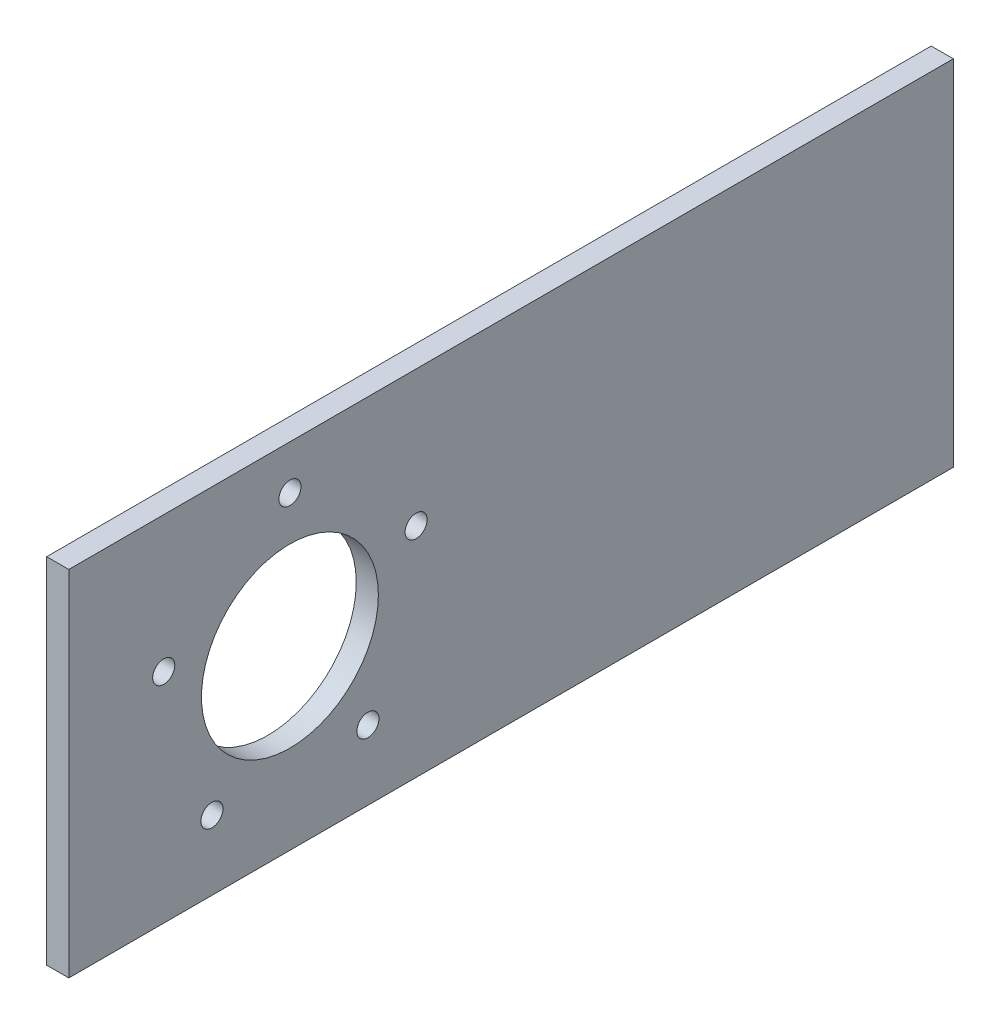
from build123d import *

# Parameters (mm, degrees)
SKETCH1_W           = 254
SKETCH1_H           = 101.6
SKETCH1_R           = 25.4
BOSS_EXTRUDE1_DEPTH = 3.175
SKETCH2_R           = 3.175
CUT_EXTRUDE1_DEPTH  = 7.35
CIRPATTERN1_COUNT   = 5


with BuildPart() as part:
    # Sketch1 → Boss-Extrude1 (new body, symmetric)
    with BuildSketch(Plane(origin=(0, 0, 0), x_dir=(0, 0, -1), z_dir=(1, 0, 0))):
        Rectangle(SKETCH1_W, SKETCH1_H)
        with Locations((-63.5, 0)):
            Circle(SKETCH1_R, mode=Mode.SUBTRACT)
    extrude(amount=BOSS_EXTRUDE1_DEPTH, both=True)

    # Sketch2 → Cut-Extrude1 (cut, through all)
    with BuildSketch(Plane(origin=(3.175, 0, 0), x_dir=(0, 0, -1), z_dir=(1, 0, 0))):
        with Locations((-63.5, 38.1)):
            Circle(SKETCH2_R)
    cut_extrude1 = extrude(amount=-CUT_EXTRUDE1_DEPTH, mode=Mode.SUBTRACT)

    # CirPattern1: Cut-Extrude1 ×5 about axis
    cirpattern1_axis = Axis((0, 0, 63.5), (1, 0, 0))
    for i in range(1, CIRPATTERN1_COUNT):
        add(cut_extrude1.rotate(cirpattern1_axis, i * 360 / CIRPATTERN1_COUNT), mode=Mode.SUBTRACT)


solid = part.part
